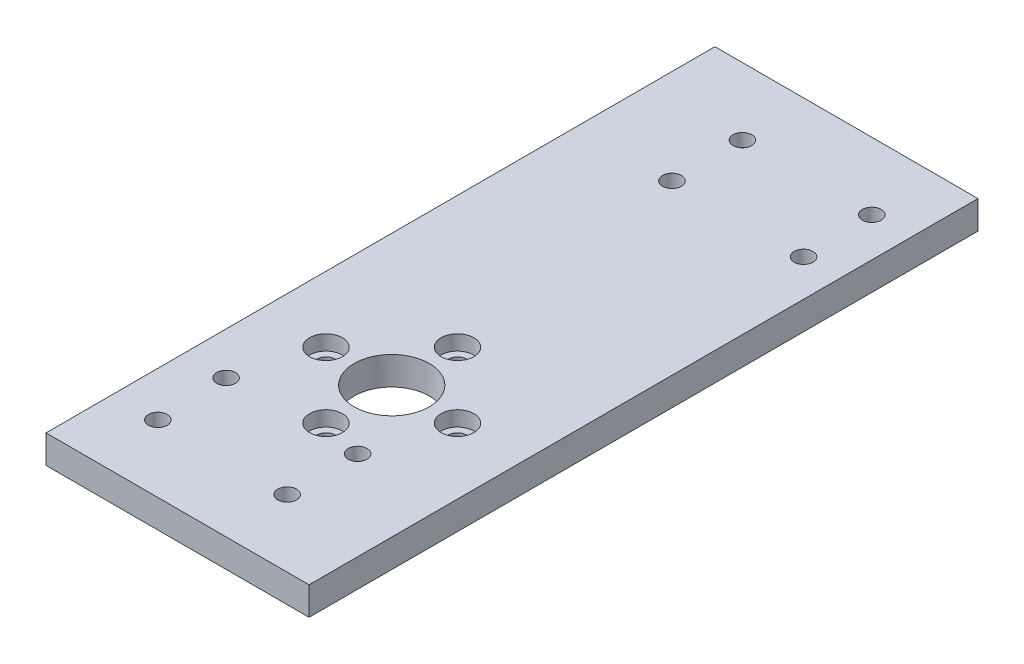
from build123d import *

# Parameters (mm, degrees)
SKETCH1_W           = 28
SKETCH1_H           = 71.2
BOSS_EXTRUDE1_DEPTH = 3
SKETCH4_R           = 1
CUT_EXTRUDE2_DEPTH  = 10
SKETCH5_R           = 4
CUT_EXTRUDE3_DEPTH  = 10
SKETCH7_R           = 1
CUT_EXTRUDE6_DEPTH  = 10
SKETCH8_R           = 1
CUT_EXTRUDE7_DEPTH  = 10
SKETCH10_R          = 1.75
CUT_EXTRUDE9_DEPTH  = 1.6
SKETCH11_R          = 1.75
CUT_EXTRUDE10_DEPTH = 1.6


with BuildPart() as part:
    # Sketch1 → Boss-Extrude1 (new body)
    with BuildSketch(Plane(origin=(0, 0, 0), x_dir=(1, 0, 0), z_dir=(0, 1, 0))):
        Rectangle(SKETCH1_W, SKETCH1_H)
    extrude(amount=BOSS_EXTRUDE1_DEPTH)

    # Sketch4 → Cut-Extrude2 (cut)
    with BuildSketch(Plane(origin=(0, 3, 0), x_dir=(1, 0, 0), z_dir=(0, 1, 0))):
        with Locations((7, -12.8)):
            Circle(SKETCH4_R)
        with Locations((0, -19.8)):
            Circle(SKETCH4_R)
        with Locations((-7, -12.8)):
            Circle(SKETCH4_R)
        with Locations((0, -5.8)):
            Circle(SKETCH4_R)
    extrude(amount=-CUT_EXTRUDE2_DEPTH, mode=Mode.SUBTRACT)

    # Sketch5 → Cut-Extrude3 (cut)
    with BuildSketch(Plane(origin=(0, 3, 0), x_dir=(1, 0, 0), z_dir=(0, 1, 0))):
        with Locations((0, -12.8)):
            Circle(SKETCH5_R)
    extrude(amount=-CUT_EXTRUDE3_DEPTH, mode=Mode.SUBTRACT)

    # Sketch7 → Cut-Extrude6 (cut)
    with BuildSketch(Plane(origin=(0, 3, 0), x_dir=(1, 0, 0), z_dir=(0, 1, 0))):
        with Locations((-9.481224865, -20.948162882)):
            Circle(SKETCH7_R)
        with Locations((-9.248832445, -28.448162882)):
            Circle(SKETCH7_R)
        with Locations((4.518775135, -28.448162882)):
            Circle(SKETCH7_R)
        with Locations((4.518775135, -20.948162882)):
            Circle(SKETCH7_R)
    extrude(amount=-CUT_EXTRUDE6_DEPTH, mode=Mode.SUBTRACT)

    # Sketch8 → Cut-Extrude7 (cut)
    with BuildSketch(Plane(origin=(0, 3, 0), x_dir=(1, 0, 0), z_dir=(0, 1, 0))):
        with Locations((-3.918775135, 28.448162882)):
            Circle(SKETCH8_R)
        with Locations((9.848832445, 28.448162882)):
            Circle(SKETCH8_R)
        with Locations((10.081224865, 20.948162882)):
            Circle(SKETCH8_R)
        with Locations((-3.918775135, 20.948162882)):
            Circle(SKETCH8_R)
    extrude(amount=-CUT_EXTRUDE7_DEPTH, mode=Mode.SUBTRACT)

    # Sketch10 → Cut-Extrude9 (cut)
    with BuildSketch(Plane(origin=(0, 3, 0), x_dir=(1, 0, 0), z_dir=(0, 1, 0))):
        with Locations((0, -19.8)):
            Circle(SKETCH10_R)
        with Locations((-7, -12.8)):
            Circle(SKETCH10_R)
        with Locations((0, -5.8)):
            Circle(SKETCH10_R)
        with Locations((7, -12.8)):
            Circle(SKETCH10_R)
    extrude(amount=-CUT_EXTRUDE9_DEPTH, mode=Mode.SUBTRACT)

    # Sketch11 → Cut-Extrude10 (cut)
    with BuildSketch(Plane.XZ):
        with Locations((-3.918775135, -20.948162882)):
            Circle(SKETCH11_R)
        with Locations((9.848832445, -28.448162882)):
            Circle(SKETCH11_R)
        with Locations((10.081224865, -20.948162882)):
            Circle(SKETCH11_R)
        with Locations((-9.248832445, 28.448162882)):
            Circle(SKETCH11_R)
        with Locations((-9.481224865, 20.948162882)):
            Circle(SKETCH11_R)
        with Locations((4.518775135, 28.448162882)):
            Circle(SKETCH11_R)
        with Locations((4.518775135, 20.948162882)):
            Circle(SKETCH11_R)
        with Locations((-3.918775135, -28.448162882)):
            Circle(SKETCH11_R)
    extrude(amount=-CUT_EXTRUDE10_DEPTH, mode=Mode.SUBTRACT)


solid = part.part
